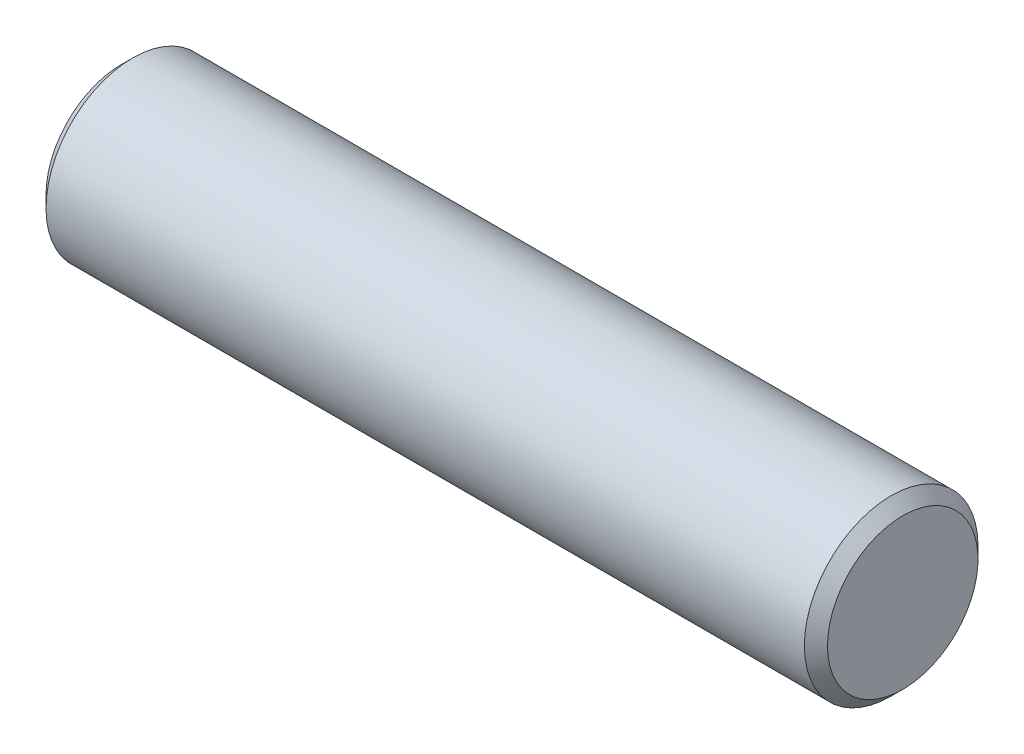
from build123d import *


with BuildPart() as part:
    # Эскиз1 → Повернуть1 (revolve)
    with BuildSketch(Plane.XY):
        Polygon((0, 0), (0, 1.3), (0.2, 1.5), (13.3, 1.5), (13.5, 1.3), (13.5, 0), align=None)
    revolve(axis=Axis((0, 0, 0), (1, 0, 0)))


solid = part.part
